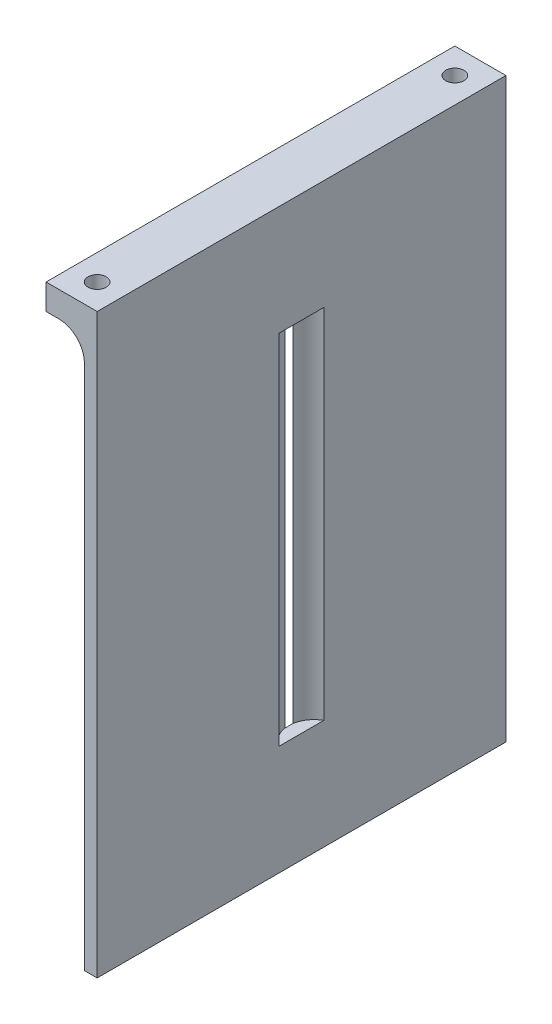
from build123d import *

# Parameters (mm, degrees)
SKETCH2_W                     = 50.8
SKETCH2_H                     = 71.73468
SKETCH2_W_2                   = 0.9906
SKETCH2_H_2                   = 44.45
BOSS_EXTRUDE1_DEPTH           = 1.5875
SKETCH3_W                     = 50.8
SKETCH3_H                     = 3.175
BOSS_EXTRUDE2_DEPTH           = 6.35
FILLET1_R                     = 3.175
TAP_DRILL_FOR_4_40_TAP1_D     = 2.2606
TAP_DRILL_FOR_4_40_TAP1_DEPTH = 6.35
TAP_DRILL_FOR_4_40_TAP1_TIP   = 0.679152758
SKETCH7_R                     = 3.175
CUT_EXTRUDE1_DEPTH            = 44.45


with BuildPart() as part:
    # Sketch2 → Boss-Extrude1 (new body)
    with BuildSketch(Plane.ZY.offset(-52.8754333)):
        Rectangle(SKETCH2_W, SKETCH2_H)
        Rectangle(SKETCH2_W_2, SKETCH2_H_2, mode=Mode.SUBTRACT)
    extrude(amount=BOSS_EXTRUDE1_DEPTH)

    # Sketch3 → Boss-Extrude2 (add)
    with BuildSketch(Plane.ZY.offset(-52.8754333)):
        with Locations((0, 34.27984)):
            Rectangle(SKETCH3_W, SKETCH3_H)
    extrude(amount=BOSS_EXTRUDE2_DEPTH)

    # Fillet1
    fillet1_edges = [part.edges().sort_by_distance(p)[0] for p in [
        (51.2879333, 32.69234, 0),
    ]]
    fillet(fillet1_edges, radius=FILLET1_R)

    # Tap Drill for #4-40 Tap1
    with Locations(Plane(origin=(0, 35.86734, 0), x_dir=(1, 0, 0), z_dir=(0, 1, 0))):
        with Locations((49.7004333, -22.225), (49.7004333, 22.225)):
            Hole(TAP_DRILL_FOR_4_40_TAP1_D / 2, depth=TAP_DRILL_FOR_4_40_TAP1_DEPTH)
            with Locations((0, 0, -(TAP_DRILL_FOR_4_40_TAP1_DEPTH + TAP_DRILL_FOR_4_40_TAP1_TIP / 2))):  # 118° drill point
                Cone(0, TAP_DRILL_FOR_4_40_TAP1_D / 2, TAP_DRILL_FOR_4_40_TAP1_TIP, mode=Mode.SUBTRACT)

    # Sketch7 → Cut-Extrude1 (cut)
    with BuildSketch(Plane.XZ.offset(-22.225)):
        with Locations((54.42406195, 0)):
            Circle(SKETCH7_R)
    extrude(amount=CUT_EXTRUDE1_DEPTH, mode=Mode.SUBTRACT)


solid = part.part
